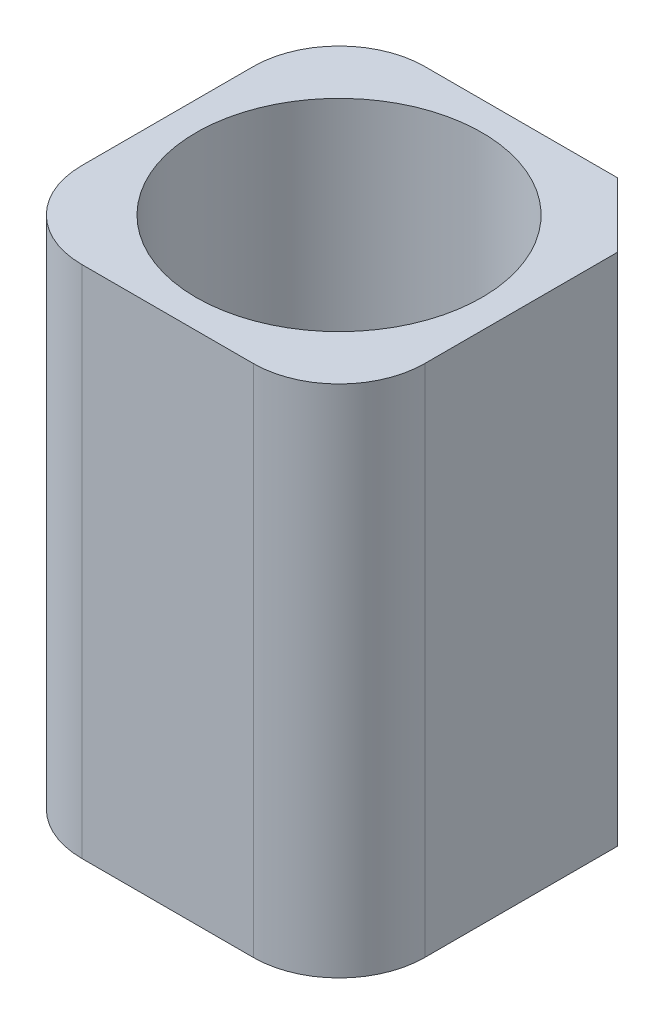
from build123d import *

# Parameters (mm, degrees)
SKETCH1_R           = 2.5
BOSS_EXTRUDE1_DEPTH = 4.5
SKETCH2_W           = 0.275
SKETCH2_H           = 0.275
CUT_EXTRUDE1_DEPTH  = 1


with BuildPart() as part:
    # Sketch1 → Boss-Extrude1 (new body, symmetric)
    with BuildSketch(Plane(origin=(0, 0, 0), x_dir=(1, 0, 0), z_dir=(0, 1, 0))):
        with BuildLine():
            Line((3, 1.875), (1.875, 3))
            Line((1.875, 3), (-1.5, 3))
            ThreePointArc((-1.5, 3), (-2.560660172, 2.560660172), (-3, 1.5))
            Line((-3, 1.5), (-3, -1.5))
            ThreePointArc((-3, -1.5), (-2.560660172, -2.560660172), (-1.5, -3))
            Line((-1.5, -3), (1.5, -3))
            ThreePointArc((1.5, -3), (2.560660172, -2.560660172), (3, -1.5))
            Line((3, -1.5), (3, 1.875))
        make_face()
        Circle(SKETCH1_R, mode=Mode.SUBTRACT)
    extrude(amount=BOSS_EXTRUDE1_DEPTH, both=True)

    # Sketch2 → Cut-Extrude1 (cut)
    with BuildSketch(Plane.XZ.offset(4.5)):
        with Locations((-2.3625, 1.6125)):
            Rectangle(SKETCH2_W, SKETCH2_H)
        with Locations((-2.1125, -2.3625)):
            Rectangle(SKETCH2_W, SKETCH2_H)
        with Locations((1.8425, -2.3625)):
            Rectangle(SKETCH2_W, SKETCH2_H)
    extrude(amount=-CUT_EXTRUDE1_DEPTH, mode=Mode.SUBTRACT)


solid = part.part
